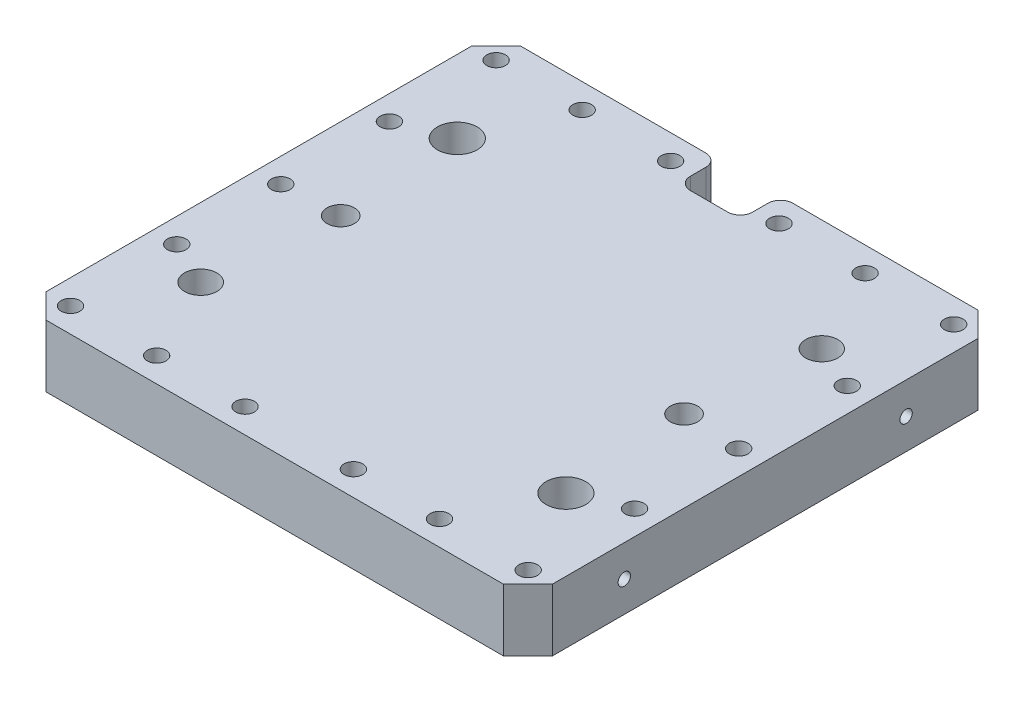
from build123d import *

# Parameters (mm, degrees)
BOSS_EXTRUDE1_DEPTH     = 12.7
SKETCH4_R               = 2.5273
CUT_EXTRUDE1_DEPTH      = 13.5636
SKETCH5_R               = 3.81
CUT_EXTRUDE2_DEPTH      = 1
CUT_EXTRUDE2_DEPTH_BACK = 26.4
SKETCH6_R               = 8.128
SKETCH6_R_2             = 5.588
SKETCH6_R_3             = 6.604
SKETCH6_R_4             = 6.5532
CUT_EXTRUDE3_DEPTH      = 12.7
SKETCH7_W               = 4.7752
SKETCH7_H               = 38.5064
SKETCH7_W_2             = 7.874
SKETCH7_H_2             = 18.415
SKETCH7_W_3             = 4.826
SKETCH7_H_3             = 38.608
CUT_EXTRUDE4_DEPTH      = 12.7
SKETCH8_R               = 5.588
CUT_EXTRUDE5_DEPTH      = 6.35


with BuildPart() as part:
    # Sketch1 → Boss-Extrude1 (new body, symmetric)
    with BuildSketch(Plane(origin=(0, 0, 0), x_dir=(1, 0, 0), z_dir=(0, 1, 0))):
        with BuildLine():
            Line((-116.078, -5.08), (-116.078, -11.3538))
            ThreePointArc((-116.078, -11.3538), (-114.590102448, -14.945902448), (-110.998, -16.4338))
            Line((-110.998, -16.4338), (-95.758, -16.4338))
            ThreePointArc((-95.758, -16.4338), (-92.165897552, -14.945902448), (-90.678, -11.3538))
            Line((-90.678, -11.3538), (-90.678, -5.08))
            ThreePointArc((-90.678, -5.08), (-89.190102448, -1.487897552), (-85.598, 0))
            Line((-85.598, 0), (-10, 0))
            Line((-10, 0), (0, -10))
            Line((0, -10), (0, -183.7766))
            Line((0, -183.7766), (-10, -193.7766))
            Line((-10, -193.7766), (-196.756, -193.7766))
            Line((-196.756, -193.7766), (-206.756, -183.7766))
            Line((-206.756, -183.7766), (-206.756, -10))
            Line((-206.756, -10), (-196.756, 0))
            Line((-196.756, 0), (-121.158, 0))
            ThreePointArc((-121.158, 0), (-117.565897552, -1.487897552), (-116.078, -5.08))
        make_face()
    extrude(amount=BOSS_EXTRUDE1_DEPTH, both=True)

    # Sketch4 → Cut-Extrude1 (cut)
    with BuildSketch(Plane(origin=(0, 0, 0), x_dir=(0, 0, -1), z_dir=(1, 0, 0))):
        with Locations((-39.3573, -0.2032)):
            Circle(SKETCH4_R)
        with Locations((-154.4193, -0.2032)):
            Circle(SKETCH4_R)
    cut_extrude1 = extrude(amount=-CUT_EXTRUDE1_DEPTH, mode=Mode.SUBTRACT)

    # Mirror1: Cut-Extrude1 across plane
    add(cut_extrude1.mirror(Plane(origin=(-103.378, 0, 0), x_dir=(0, 0, 1), z_dir=(1, 0, 0))), mode=Mode.SUBTRACT)

    # Sketch5 → Cut-Extrude2 (cut, two sides)
    with BuildSketch(Plane(origin=(0, 12.7, 0), x_dir=(1, 0, 0), z_dir=(0, 1, 0))) as cut_extrude2_sk:
        with Locations((-196.7484, -10.0076)):
            Circle(SKETCH5_R)
        with Locations((-161.5948, -10.0076)):
            Circle(SKETCH5_R)
        with Locations((-125.5014, -10.0076)):
            Circle(SKETCH5_R)
        with Locations((-81.2546, -10.0076)):
            Circle(SKETCH5_R)
        with Locations((-9.906, -183.769)):
            Circle(SKETCH5_R)
        with Locations((-46.101, -183.769)):
            Circle(SKETCH5_R)
        with Locations((-81.2546, -183.769)):
            Circle(SKETCH5_R)
        with Locations((-125.5014, -183.769)):
            Circle(SKETCH5_R)
        with Locations((-161.5948, -183.769)):
            Circle(SKETCH5_R)
        with Locations((-196.7484, -183.769)):
            Circle(SKETCH5_R)
        with Locations((-9.906, -53.467)):
            Circle(SKETCH5_R)
        with Locations((-9.906, -97.8154)):
            Circle(SKETCH5_R)
        with Locations((-9.906, -140.3096)):
            Circle(SKETCH5_R)
        with Locations((-196.85, -53.467)):
            Circle(SKETCH5_R)
        with Locations((-196.85, -97.8154)):
            Circle(SKETCH5_R)
        with Locations((-196.85, -140.3096)):
            Circle(SKETCH5_R)
        with Locations((-46.101, -10.0076)):
            Circle(SKETCH5_R)
        with Locations((-9.906, -10.0076)):
            Circle(SKETCH5_R)
    extrude(amount=CUT_EXTRUDE2_DEPTH, mode=Mode.SUBTRACT)
    extrude(cut_extrude2_sk.sketch, amount=-CUT_EXTRUDE2_DEPTH_BACK, mode=Mode.SUBTRACT)

    # Sketch6 → Cut-Extrude3 (cut)
    with BuildSketch(Plane(origin=(0, 12.7, 0), x_dir=(1, 0, 0), z_dir=(0, 1, 0))):
        with Locations((-177.038, -45.5676)):
            Circle(SKETCH6_R)
        with Locations((-173.482, -96.7232)):
            Circle(SKETCH6_R_2)
        with Locations((-178.562, -148.8186)):
            Circle(SKETCH6_R_3)
        with Locations((-28.2321, -45.5676)):
            Circle(SKETCH6_R_4)
        with Locations((-33.2994, -96.7232)):
            Circle(SKETCH6_R_2)
        with Locations((-29.4386, -148.8186)):
            Circle(SKETCH6_R)
    extrude(amount=-CUT_EXTRUDE3_DEPTH, mode=Mode.SUBTRACT)

    # Sketch7 → Cut-Extrude4 (cut)
    with BuildSketch(Plane.XZ.offset(12.7)):
        with Locations((-175.6664, 53.467)):
            Rectangle(SKETCH7_W, SKETCH7_H)
        with Locations((-174.78756, 97.8154)):
            Rectangle(SKETCH7_W_2, SKETCH7_H_2)
        with Locations((-175.641, 140.3096)):
            Rectangle(SKETCH7_W_3, SKETCH7_H_3)
        with Locations((-31.115, 140.3096)):
            Rectangle(SKETCH7_W_3, SKETCH7_H_3)
        with Locations((-31.0896, 53.467)):
            Rectangle(SKETCH7_W, SKETCH7_H)
        with Locations((-31.96844, 97.8154)):
            Rectangle(SKETCH7_W_2, SKETCH7_H_2)
    extrude(amount=-CUT_EXTRUDE4_DEPTH, mode=Mode.SUBTRACT)

    # Sketch8 → Cut-Extrude5 (cut)
    with BuildSketch(Plane.XZ.offset(12.7)):
        with Locations((-191.5414, 119.0244)):
            Circle(SKETCH8_R)
        with Locations((-191.5414, 74.7522)):
            Circle(SKETCH8_R)
        with Locations((-15.2146, 74.7522)):
            Circle(SKETCH8_R)
        with Locations((-15.2146, 119.0244)):
            Circle(SKETCH8_R)
    extrude(amount=-CUT_EXTRUDE5_DEPTH, mode=Mode.SUBTRACT)


solid = part.part
